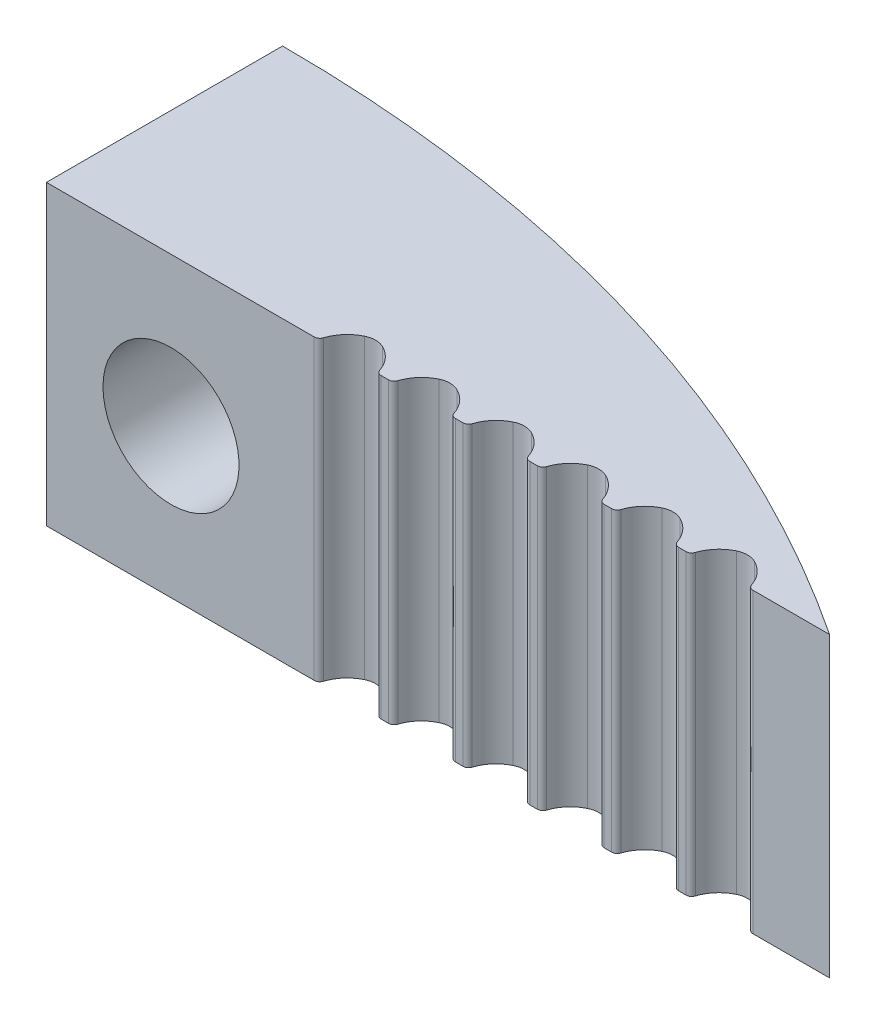
from build123d import *

# Parameters (mm, degrees)
BOSS_EXTRUDE1_DEPTH                            = 8
CBORE_FOR_6_SOCKET_HEAD_CAP_SCREW1_D           = 3.6576
CBORE_FOR_6_SOCKET_HEAD_CAP_SCREW1_CBORE_D     = 6.35
CBORE_FOR_6_SOCKET_HEAD_CAP_SCREW1_CBORE_DEPTH = 3.5052
CUT_EXTRUDE1_DEPTH                             = 9.0000001


with BuildPart() as part:
    # Sketch1 → Boss-Extrude1 (new body)
    with BuildSketch(Plane(origin=(0, 0, 0), x_dir=(1, 0, 0), z_dir=(0, 1, 0))):
        with BuildLine():
            Line((0, 0), (0, 6.35))
            ThreePointArc((0, 6.35), (10.998522628, 4.727972806), (21.060567419, 0))
            Line((21.060567419, 0), (0, 0))
        make_face()
    extrude(amount=BOSS_EXTRUDE1_DEPTH)

    # CBORE for #6 Socket Head Cap Screw1 (through all)
    with Locations(Plane(origin=(0, 0, -6.35), x_dir=(-1, 0, 0), z_dir=(0, 0, -1))):
        with Locations((-3.35, 4)):
            CounterBoreHole(CBORE_FOR_6_SOCKET_HEAD_CAP_SCREW1_D / 2, CBORE_FOR_6_SOCKET_HEAD_CAP_SCREW1_CBORE_D / 2, CBORE_FOR_6_SOCKET_HEAD_CAP_SCREW1_CBORE_DEPTH)

    # Sketch8 → Cut-Extrude1 (cut, through all)
    with BuildSketch(Plane.XZ):
        with BuildLine():
            Line((7.202330007, 0), (7, 0))
            Line((7, 0), (7, 1.396675329))
            Line((7, 1.396675329), (19, 1.396675329))
            Line((19, 1.396675329), (19, 0))
            ThreePointArc((19, 0), (18.911811713, -0.028662347), (18.85732587, -0.103695652))
            ThreePointArc((18.85732587, -0.103695652), (18.66092377, -0.451002442), (18.34436725, -0.693876404))
            ThreePointArc((18.34436725, -0.693876404), (18.101165003, -0.75), (17.857962756, -0.693876404))
            ThreePointArc((17.857962756, -0.693876404), (17.541406237, -0.451002442), (17.345004137, -0.103695652))
            ThreePointArc((17.345004137, -0.103695652), (17.290518293, -0.028662347), (17.202330007, 0))
            Line((17.202330007, 0), (17, 0))
            ThreePointArc((17, 0), (16.911811713, -0.028662347), (16.85732587, -0.103695652))
            ThreePointArc((16.85732587, -0.103695652), (16.66092377, -0.451002442), (16.34436725, -0.693876404))
            ThreePointArc((16.34436725, -0.693876404), (16.101165003, -0.75), (15.857962756, -0.693876404))
            ThreePointArc((15.857962756, -0.693876404), (15.541406237, -0.451002442), (15.345004137, -0.103695652))
            ThreePointArc((15.345004137, -0.103695652), (15.290518293, -0.028662347), (15.202330007, 0))
            Line((15.202330007, 0), (15, 0))
            ThreePointArc((15, 0), (14.911811713, -0.028662347), (14.85732587, -0.103695652))
            ThreePointArc((14.85732587, -0.103695652), (14.66092377, -0.451002442), (14.34436725, -0.693876404))
            ThreePointArc((14.34436725, -0.693876404), (14.101165003, -0.75), (13.857962756, -0.693876404))
            ThreePointArc((13.857962756, -0.693876404), (13.541406237, -0.451002442), (13.345004137, -0.103695652))
            ThreePointArc((13.345004137, -0.103695652), (13.290518293, -0.028662347), (13.202330007, 0))
            Line((13.202330007, 0), (13, 0))
            ThreePointArc((13, 0), (12.911811713, -0.028662347), (12.85732587, -0.103695652))
            ThreePointArc((12.85732587, -0.103695652), (12.66092377, -0.451002442), (12.34436725, -0.693876404))
            ThreePointArc((12.34436725, -0.693876404), (12.101165003, -0.75), (11.857962756, -0.693876404))
            ThreePointArc((11.857962756, -0.693876404), (11.541406237, -0.451002442), (11.345004137, -0.103695652))
            ThreePointArc((11.345004137, -0.103695652), (11.290518293, -0.028662347), (11.202330007, 0))
            Line((11.202330007, 0), (11, 0))
            ThreePointArc((11, 0), (10.911811713, -0.028662347), (10.85732587, -0.103695652))
            ThreePointArc((10.85732587, -0.103695652), (10.66092377, -0.451002442), (10.34436725, -0.693876404))
            ThreePointArc((10.34436725, -0.693876404), (10.101165003, -0.75), (9.857962756, -0.693876404))
            ThreePointArc((9.857962756, -0.693876404), (9.541406237, -0.451002442), (9.345004137, -0.103695652))
            ThreePointArc((9.345004137, -0.103695652), (9.290518293, -0.028662347), (9.202330007, 0))
            Line((9.202330007, 0), (9, 0))
            ThreePointArc((9, 0), (8.911811713, -0.028662347), (8.85732587, -0.103695652))
            ThreePointArc((8.85732587, -0.103695652), (8.66092377, -0.451002442), (8.34436725, -0.693876404))
            ThreePointArc((8.34436725, -0.693876404), (8.101165003, -0.75), (7.857962756, -0.693876404))
            ThreePointArc((7.857962756, -0.693876404), (7.541406237, -0.451002442), (7.345004137, -0.103695652))
            ThreePointArc((7.345004137, -0.103695652), (7.290518293, -0.028662347), (7.202330007, 0))
        make_face()
    extrude(amount=-CUT_EXTRUDE1_DEPTH, mode=Mode.SUBTRACT)


solid = part.part
